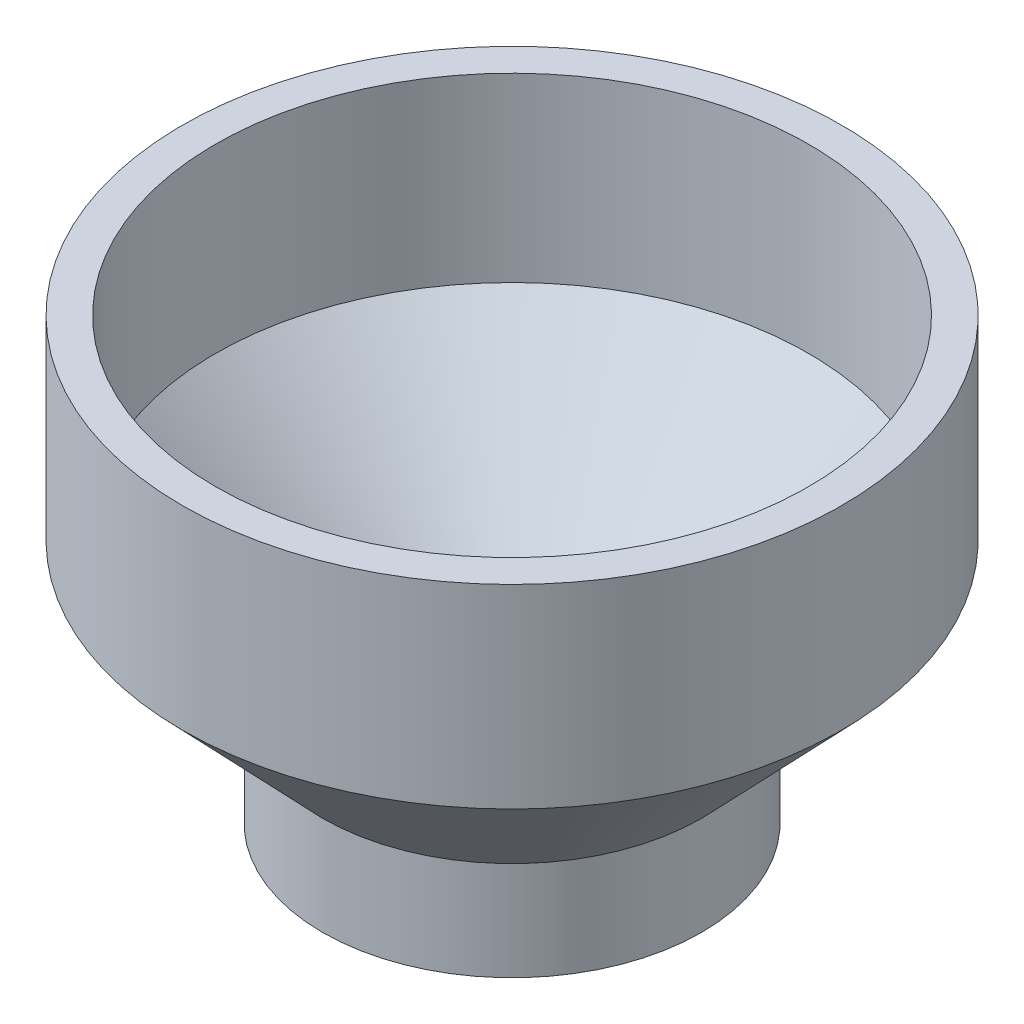
from build123d import *


with BuildPart() as part:
    # Sketch1 → Revolve-Thin1 (revolve)
    with BuildSketch(Plane.XY):
        Polygon((-30.1625, 0), (-30.1625, 21.59), (-57.15, 49.784), (-57.15, 84.709), (-63.5, 84.709), (-63.5, 47.234696899), (-36.5125, 19.040696899), (-36.5125, 0), align=None)
    revolve(axis=Axis((0, 0, 0), (0, -1, 0)))


solid = part.part
